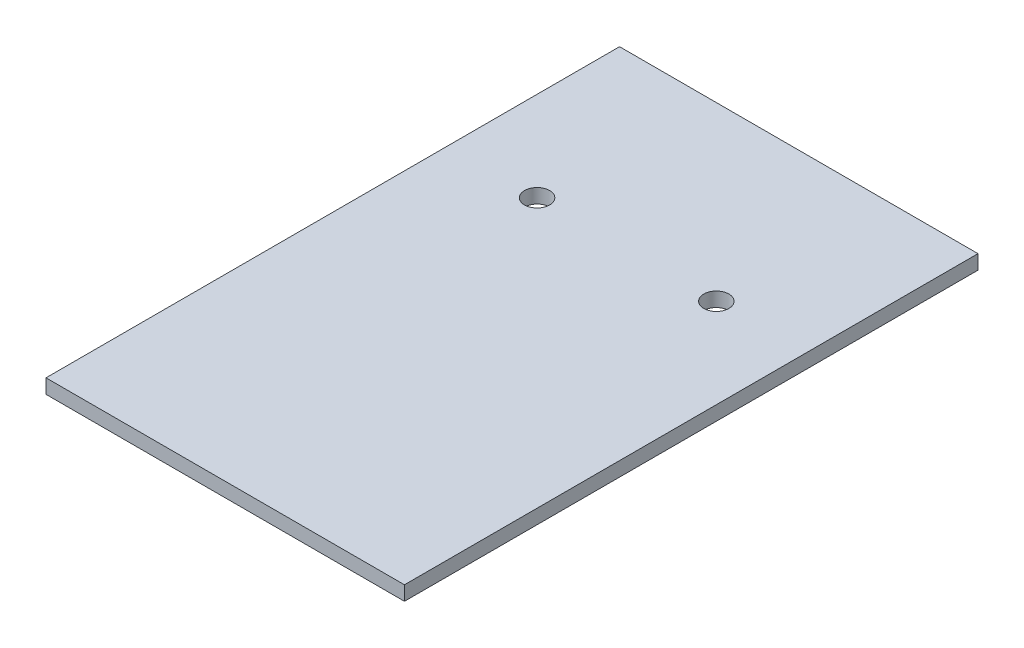
from build123d import *

# Parameters (mm, degrees)
ESQUISSE1_W             = 50
ESQUISSE1_H             = 80
BOSS_EXTRU_1_DEPTH      = 2
ENL_V_MAT_EXTRU_1_REACH = 4
ESQUISSE2_R             = 1.75


with BuildPart() as part:
    # Esquisse1 → Boss.-Extru.1 (new body)
    with BuildSketch(Plane(origin=(0, 0, 0), x_dir=(1, 0, 0), z_dir=(0, 1, 0))):
        with Locations((25, 40)):
            Rectangle(ESQUISSE1_W, ESQUISSE1_H)
    extrude(amount=BOSS_EXTRU_1_DEPTH)

    # Esquisse2 → Enlèv. mat.-Extru.1 (cut, up to next)
    with BuildSketch(Plane(origin=(0, 2, 0), x_dir=(1, 0, 0), z_dir=(0, 1, 0)), mode=Mode.PRIVATE) as enl_v_mat_extru_1_sk1:
        with Locations((12.5, 56)):
            Circle(ESQUISSE2_R)
    enl_v_mat_extru_1_tool1 = extrude(enl_v_mat_extru_1_sk1.sketch, amount=-ENL_V_MAT_EXTRU_1_REACH, mode=Mode.PRIVATE) & part.part
    add(enl_v_mat_extru_1_tool1.solids().sort_by_distance((12.5, 2, -56))[0], mode=Mode.SUBTRACT)
    # Esquisse2 → Enlèv. mat.-Extru.1 (cut, up to next)
    with BuildSketch(Plane(origin=(0, 2, 0), x_dir=(1, 0, 0), z_dir=(0, 1, 0)), mode=Mode.PRIVATE) as enl_v_mat_extru_1_sk2:
        with Locations((37.5, 56)):
            Circle(ESQUISSE2_R)
    enl_v_mat_extru_1_tool2 = extrude(enl_v_mat_extru_1_sk2.sketch, amount=-ENL_V_MAT_EXTRU_1_REACH, mode=Mode.PRIVATE) & part.part
    add(enl_v_mat_extru_1_tool2.solids().sort_by_distance((37.5, 2, -56))[0], mode=Mode.SUBTRACT)


solid = part.part
